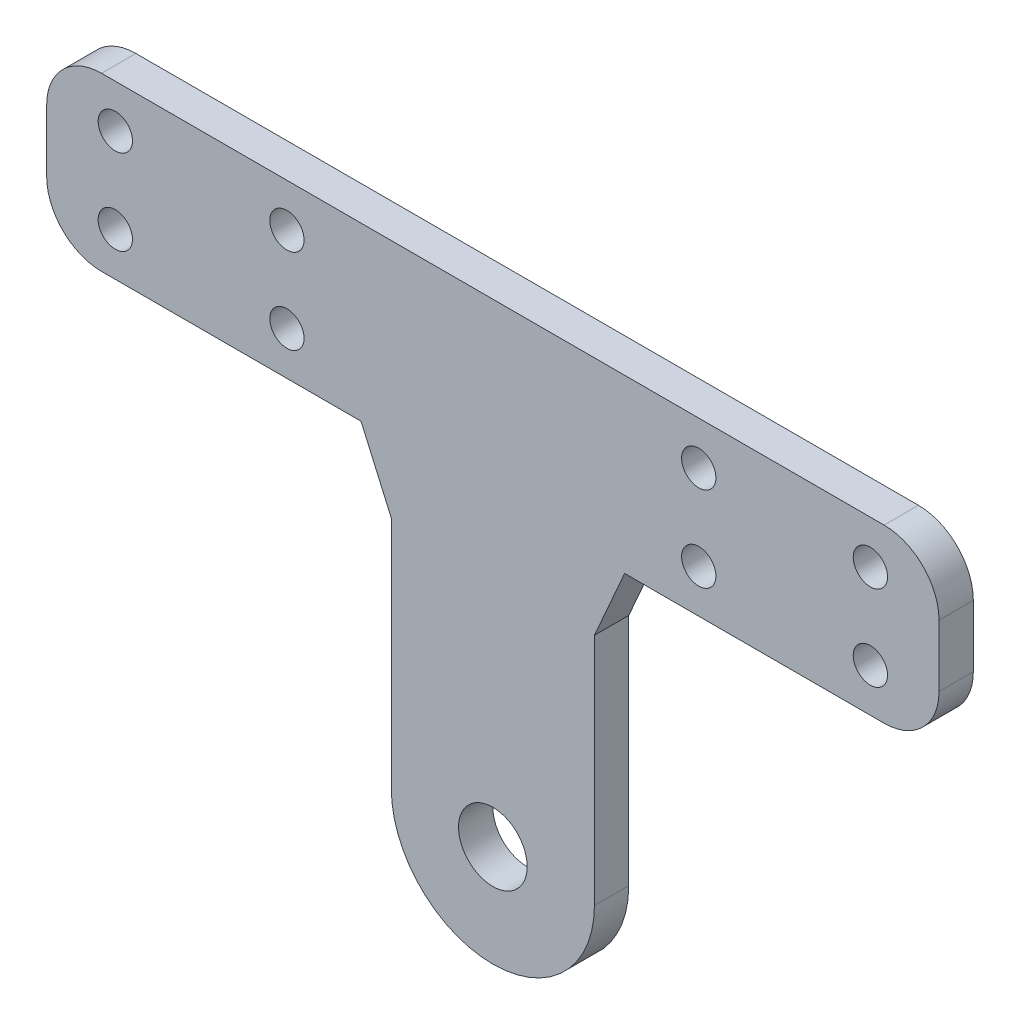
from build123d import *

# Parameters (mm, degrees)
SKETCH1_R           = 3.175
SKETCH1_R_2         = 1.5875
BOSS_EXTRUDE1_DEPTH = 3.175
FILLET1_R           = 5.08


with BuildPart() as part:
    # Sketch1 → Boss-Extrude1 (new body)
    with BuildSketch(Plane.XY):
        with BuildLine():
            Line((-41.275, 43.879), (41.275, 43.879))
            Line((41.275, 43.879), (41.275, 28.004))
            Line((41.275, 28.004), (12.192, 28.004))
            Line((12.192, 28.004), (9.398, 21.654))
            Line((9.398, 21.654), (9.398, 0))
            ThreePointArc((9.398, 0), (0, -9.398), (-9.398, 0))
            Line((-9.398, 0), (-9.398, 21.654))
            Line((-9.398, 21.654), (-12.192, 28.004))
            Line((-12.192, 28.004), (-41.275, 28.004))
            Line((-41.275, 28.004), (-41.275, 43.879))
        make_face()
        Circle(SKETCH1_R, mode=Mode.SUBTRACT)
        with Locations((-19.05, 32.004)):
            Circle(SKETCH1_R_2, mode=Mode.SUBTRACT)
        with Locations((-34.925, 32.004)):
            Circle(SKETCH1_R_2, mode=Mode.SUBTRACT)
        with Locations((34.925, 32.004)):
            Circle(SKETCH1_R_2, mode=Mode.SUBTRACT)
        with Locations((19.05, 32.004)):
            Circle(SKETCH1_R_2, mode=Mode.SUBTRACT)
        with Locations((-19.05, 39.879)):
            Circle(SKETCH1_R_2, mode=Mode.SUBTRACT)
        with Locations((-34.925, 39.879)):
            Circle(SKETCH1_R_2, mode=Mode.SUBTRACT)
        with Locations((34.925, 39.879)):
            Circle(SKETCH1_R_2, mode=Mode.SUBTRACT)
        with Locations((19.05, 39.879)):
            Circle(SKETCH1_R_2, mode=Mode.SUBTRACT)
    extrude(amount=BOSS_EXTRUDE1_DEPTH)

    # Fillet1
    fillet1_edges = [part.edges().sort_by_distance(p)[0] for p in [
        (41.275, 28.004, 1.5875),
        (41.275, 43.879, 1.5875),
        (-41.275, 28.004, 1.5875),
        (-41.275, 43.879, 1.5875),
    ]]
    fillet(fillet1_edges, radius=FILLET1_R)


solid = part.part
